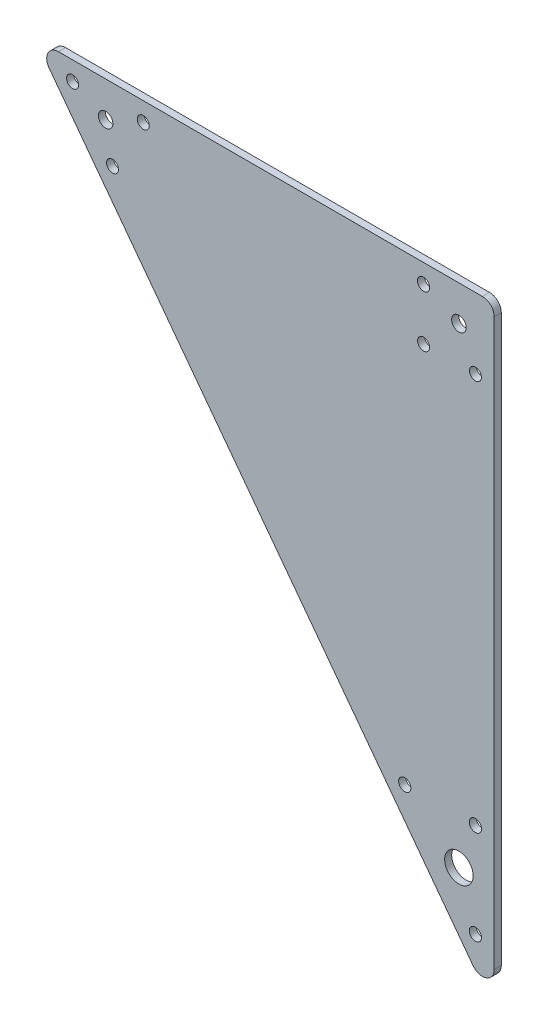
from build123d import *

# Parameters (mm, degrees)
SKETCH_2_R      = 3.1
SKETCH_2_R_2    = 6.05
SKETCH_2_R_3    = 2.55
SKETCH_2_R_4    = 2.6
EXTRUDE_1_DEPTH = 3
FILLET_1_R      = 5


with BuildPart() as part:
    # 草图2 → 凸台-拉伸1 (new body)
    with BuildSketch(Plane.XY):
        Polygon((-180, 15), (15, 15), (15, -245), align=None)
        Circle(SKETCH_2_R, mode=Mode.SUBTRACT)
        with Locations((-150, 0)):
            Circle(SKETCH_2_R, mode=Mode.SUBTRACT)
        with Locations((0, -200)):
            Circle(SKETCH_2_R_2, mode=Mode.SUBTRACT)
        with Locations((-164, 7)):
            Circle(SKETCH_2_R_3, mode=Mode.SUBTRACT)
        with Locations((-134, 7)):
            Circle(SKETCH_2_R_3, mode=Mode.SUBTRACT)
        with Locations((-147.04893552, -15.601419306)):
            Circle(SKETCH_2_R_3, mode=Mode.SUBTRACT)
        with Locations((-15, 7)):
            Circle(SKETCH_2_R_4, mode=Mode.SUBTRACT)
        with Locations((7, -15)):
            Circle(SKETCH_2_R_3, mode=Mode.SUBTRACT)
        with Locations((7, -221)):
            Circle(SKETCH_2_R_4, mode=Mode.SUBTRACT)
        with Locations((-23, -181)):
            Circle(SKETCH_2_R_4, mode=Mode.SUBTRACT)
        with Locations((7, -181)):
            Circle(SKETCH_2_R_4, mode=Mode.SUBTRACT)
        with Locations((-15, -15)):
            Circle(SKETCH_2_R_3, mode=Mode.SUBTRACT)
    extrude(amount=EXTRUDE_1_DEPTH)

    # 圆角1
    fillet_1_edges = [part.edges().sort_by_distance(p)[0] for p in [
        (-180, 15, 1.5),
        (15, 15, 1.5),
        (15, -245, 1.5),
    ]]
    fillet(fillet_1_edges, radius=FILLET_1_R)


solid = part.part
